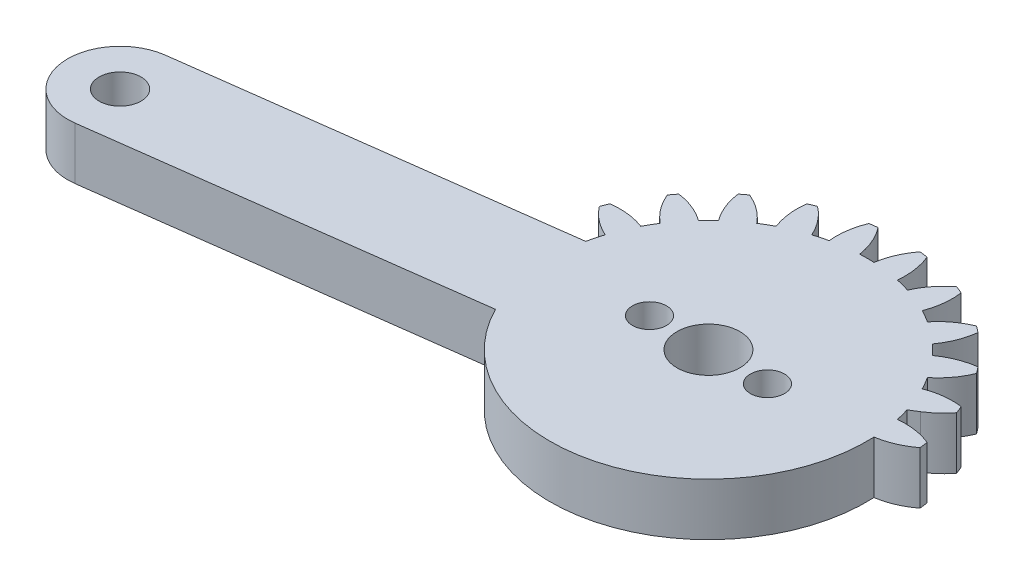
from build123d import *

# Parameters (mm, degrees)
SKETCH1_R           = 1.5
SKETCH1_R_2         = 1.6
BOSS_EXTRUDE1_DEPTH = 4
SKETCH3_R           = 1.6
BOSS_EXTRUDE2_DEPTH = 4
CUT_EXTRUDE1_DEPTH  = 4
CUT_EXTRUDE2_REACH  = 6
SKETCH5_R           = 1.3
SKETCH5_R_2         = 2.4


with BuildPart() as part:
    # Sketch1 → Boss-Extrude1 (new body)
    with BuildSketch(Plane(origin=(0, 0, 0), x_dir=(1, 0, 0), z_dir=(0, 1, 0))):
        with BuildLine():
            Line((20.643657446, 4), (2.081641936, 4))
            ThreePointArc((2.081641936, 4), (2.861028333, 4.588201733), (3.521749436, 5.30713988))
            ThreePointArc((3.521749436, 5.30713988), (3.405395609, 5.596745198), (3.282888305, 5.883801663))
            ThreePointArc((3.282888305, 5.883801663), (1.93527598, 5.894040025), (0.627094961, 5.57027124))
            ThreePointArc((0.627094961, 5.57027124), (0.366286148, 6.046375), (0.084372603, 6.510293938))
            ThreePointArc((0.084372603, 6.510293938), (1.018855105, 7.48132754), (1.683794586, 8.65351323))
            ThreePointArc((1.683794586, 8.65351323), (1.496450048, 8.903135899), (1.303821399, 9.148703928))
            ThreePointArc((1.303821399, 9.148703928), (-0.000522033, 8.809805691), (-1.180330337, 8.158486898))
            ThreePointArc((-1.180330337, 8.158486898), (-1.555477026, 8.550865528), (-1.947855656, 8.926012217))
            ThreePointArc((-1.947855656, 8.926012217), (-1.296536862, 10.105820521), (-0.957638625, 11.410163953))
            ThreePointArc((-0.957638625, 11.410163953), (-1.203206655, 11.602792602), (-1.452829324, 11.79013714))
            ThreePointArc((-1.452829324, 11.79013714), (-2.625015014, 11.125197659), (-3.596048616, 10.190715157))
            ThreePointArc((-3.596048616, 10.190715157), (-4.059967554, 10.472628702), (-4.536071314, 10.733437515))
            ThreePointArc((-4.536071314, 10.733437515), (-4.212302529, 12.041618533), (-4.222540891, 13.389230859))
            ThreePointArc((-4.222540891, 13.389230859), (-4.509597355, 13.511738163), (-4.799202674, 13.62809199))
            ThreePointArc((-4.799202674, 13.62809199), (-5.759348103, 12.682425791), (-6.455432668, 11.528463019))
            ThreePointArc((-6.455432668, 11.528463019), (-6.976508546, 11.680699536), (-7.503891752, 11.809396783))
            ThreePointArc((-7.503891752, 11.809396783), (-7.529737283, 13.156800143), (-7.888414517, 14.455843809))
            ThreePointArc((-7.888414517, 14.455843809), (-8.197396993, 14.499881098), (-8.507248835, 14.537314892))
            ThreePointArc((-8.507248835, 14.537314892), (-9.18992168, 13.375367565), (-9.563620196, 12.080565177))
            ThreePointArc((-9.563620196, 12.080565177), (-10.106342554, 12.09275), (-10.649064912, 12.080565177))
            ThreePointArc((-10.649064912, 12.080565177), (-11.022763428, 13.375367565), (-11.705436272, 14.537314892))
            ThreePointArc((-11.705436272, 14.537314892), (-12.015288115, 14.499881098), (-12.324270591, 14.455843809))
            ThreePointArc((-12.324270591, 14.455843809), (-12.682947825, 13.156800143), (-12.708793355, 11.809396783))
            ThreePointArc((-12.708793355, 11.809396783), (-13.236176561, 11.680699536), (-13.757252439, 11.528463019))
            ThreePointArc((-13.757252439, 11.528463019), (-14.453337005, 12.682425791), (-15.413482434, 13.62809199))
            ThreePointArc((-15.413482434, 13.62809199), (-15.703087752, 13.511738163), (-15.990144217, 13.389230859))
            ThreePointArc((-15.990144217, 13.389230859), (-16.000382579, 12.041618533), (-15.676613793, 10.733437515))
            ThreePointArc((-15.676613793, 10.733437515), (-16.152717554, 10.472628702), (-16.616636492, 10.190715157))
            ThreePointArc((-16.616636492, 10.190715157), (-17.587670094, 11.125197659), (-18.759855783, 11.79013714))
            ThreePointArc((-18.759855783, 11.79013714), (-19.009478453, 11.602792602), (-19.255046482, 11.410163953))
            ThreePointArc((-19.255046482, 11.410163953), (-18.916148245, 10.105820521), (-18.264829452, 8.926012217))
            ThreePointArc((-18.264829452, 8.926012217), (-18.657208082, 8.550865528), (-19.032354771, 8.158486898))
            ThreePointArc((-19.032354771, 8.158486898), (-20.212163074, 8.809805691), (-21.516506507, 9.148703928))
            ThreePointArc((-21.516506507, 9.148703928), (-21.709135156, 8.903135899), (-21.896479694, 8.65351323))
            ThreePointArc((-21.896479694, 8.65351323), (-21.231540213, 7.48132754), (-20.297057711, 6.510293938))
            ThreePointArc((-20.297057711, 6.510293938), (-20.578971255, 6.046375), (-20.839780068, 5.57027124))
            ThreePointArc((-20.839780068, 5.57027124), (-22.147961087, 5.894040025), (-23.495573413, 5.883801663))
            ThreePointArc((-23.495573413, 5.883801663), (-23.618080717, 5.596745198), (-23.734434544, 5.30713988))
            ThreePointArc((-23.734434544, 5.30713988), (-22.788768345, 4.346994451), (-21.634805572, 3.650909885))
            ThreePointArc((-21.634805572, 3.650909885), (-21.78704209, 3.129834008), (-21.915739337, 2.602450802))
            ThreePointArc((-21.915739337, 2.602450802), (-23.263142697, 2.576605271), (-24.562186363, 2.217928037))
            ThreePointArc((-24.562186363, 2.217928037), (-24.606223651, 1.908945561), (-24.643657446, 1.599093719))
            ThreePointArc((-24.643657446, 1.599093719), (-23.481710119, 0.916420874), (-22.186907731, 0.542722358))
            ThreePointArc((-22.186907731, 0.542722358), (-22.199092554, 0), (-22.186907731, -0.542722358))
            ThreePointArc((-22.186907731, -0.542722358), (-23.481710119, -0.916420874), (-24.643657446, -1.599093719))
            ThreePointArc((-24.643657446, -1.599093719), (-24.606223651, -1.908945561), (-24.562186363, -2.217928037))
            ThreePointArc((-24.562186363, -2.217928037), (-23.263142697, -2.576605271), (-21.915739337, -2.602450802))
            ThreePointArc((-21.915739337, -2.602450802), (-21.78704209, -3.129834008), (-21.634805572, -3.650909885))
            ThreePointArc((-21.634805572, -3.650909885), (-22.788768345, -4.346994451), (-23.734434544, -5.30713988))
            ThreePointArc((-23.734434544, -5.30713988), (-23.618080717, -5.596745198), (-23.495573413, -5.883801663))
            ThreePointArc((-23.495573413, -5.883801663), (-22.147961087, -5.894040025), (-20.839780068, -5.57027124))
            ThreePointArc((-20.839780068, -5.57027124), (-20.578971255, -6.046375), (-20.297057711, -6.510293938))
            ThreePointArc((-20.297057711, -6.510293938), (-21.231540213, -7.48132754), (-21.896479694, -8.65351323))
            ThreePointArc((-21.896479694, -8.65351323), (-21.709135156, -8.903135899), (-21.516506507, -9.148703928))
            ThreePointArc((-21.516506507, -9.148703928), (-20.212163074, -8.809805691), (-19.032354771, -8.158486898))
            ThreePointArc((-19.032354771, -8.158486898), (-18.657208082, -8.550865528), (-18.264829452, -8.926012217))
            ThreePointArc((-18.264829452, -8.926012217), (-18.916148245, -10.105820521), (-19.255046482, -11.410163953))
            ThreePointArc((-19.255046482, -11.410163953), (-19.009478453, -11.602792602), (-18.759855783, -11.79013714))
            ThreePointArc((-18.759855783, -11.79013714), (-17.587670094, -11.125197659), (-16.616636492, -10.190715157))
            ThreePointArc((-16.616636492, -10.190715157), (-16.152717554, -10.472628702), (-15.676613793, -10.733437515))
            ThreePointArc((-15.676613793, -10.733437515), (-16.000382579, -12.041618533), (-15.990144217, -13.389230859))
            ThreePointArc((-15.990144217, -13.389230859), (-15.703087752, -13.511738163), (-15.413482434, -13.62809199))
            ThreePointArc((-15.413482434, -13.62809199), (-14.453337005, -12.682425791), (-13.757252439, -11.528463019))
            ThreePointArc((-13.757252439, -11.528463019), (-13.236176561, -11.680699536), (-12.708793355, -11.809396783))
            ThreePointArc((-12.708793355, -11.809396783), (-12.682947825, -13.156800143), (-12.324270591, -14.455843809))
            ThreePointArc((-12.324270591, -14.455843809), (-12.015288115, -14.499881098), (-11.705436272, -14.537314892))
            ThreePointArc((-11.705436272, -14.537314892), (-11.022763428, -13.375367565), (-10.649064912, -12.080565177))
            ThreePointArc((-10.649064912, -12.080565177), (-10.106342554, -12.09275), (-9.563620196, -12.080565177))
            ThreePointArc((-9.563620196, -12.080565177), (-9.18992168, -13.375367565), (-8.507248835, -14.537314892))
            ThreePointArc((-8.507248835, -14.537314892), (-8.197396993, -14.499881098), (-7.888414517, -14.455843809))
            ThreePointArc((-7.888414517, -14.455843809), (-7.529737283, -13.156800143), (-7.503891752, -11.809396783))
            ThreePointArc((-7.503891752, -11.809396783), (-6.976508546, -11.680699536), (-6.455432668, -11.528463019))
            ThreePointArc((-6.455432668, -11.528463019), (-5.759348103, -12.682425791), (-4.799202674, -13.62809199))
            ThreePointArc((-4.799202674, -13.62809199), (-4.509597355, -13.511738163), (-4.222540891, -13.389230859))
            ThreePointArc((-4.222540891, -13.389230859), (-4.212302529, -12.041618533), (-4.536071314, -10.733437515))
            ThreePointArc((-4.536071314, -10.733437515), (-4.059967554, -10.472628702), (-3.596048616, -10.190715157))
            ThreePointArc((-3.596048616, -10.190715157), (-2.625015014, -11.125197659), (-1.452829324, -11.79013714))
            ThreePointArc((-1.452829324, -11.79013714), (-1.203206655, -11.602792602), (-0.957638625, -11.410163953))
            ThreePointArc((-0.957638625, -11.410163953), (-1.296536862, -10.105820521), (-1.947855656, -8.926012217))
            ThreePointArc((-1.947855656, -8.926012217), (-1.555477026, -8.550865528), (-1.180330337, -8.158486898))
            ThreePointArc((-1.180330337, -8.158486898), (-0.000522033, -8.809805691), (1.303821399, -9.148703928))
            ThreePointArc((1.303821399, -9.148703928), (1.496450048, -8.903135899), (1.683794586, -8.65351323))
            ThreePointArc((1.683794586, -8.65351323), (1.018855105, -7.48132754), (0.084372603, -6.510293938))
            ThreePointArc((0.084372603, -6.510293938), (0.366286148, -6.046375), (0.627094961, -5.57027124))
            ThreePointArc((0.627094961, -5.57027124), (1.93527598, -5.894040025), (3.282888305, -5.883801663))
            ThreePointArc((3.282888305, -5.883801663), (3.405395609, -5.596745198), (3.521749436, -5.30713988))
            ThreePointArc((3.521749436, -5.30713988), (2.861028333, -4.588201733), (2.081641936, -4))
            Line((2.081641936, -4), (20.643657446, -4))
            ThreePointArc((20.643657446, -4), (24.643657446, 0), (20.643657446, 4))
        make_face()
        with Locations((-10.106342554, 0)):
            Circle(SKETCH1_R, mode=Mode.SUBTRACT)
        with Locations((20.643657446, 0)):
            Circle(SKETCH1_R_2, mode=Mode.SUBTRACT)
    extrude(amount=BOSS_EXTRUDE1_DEPTH)

    # Sketch3 → Boss-Extrude2 (add)
    with BuildSketch(Plane(origin=(0, 4, 0), x_dir=(1, 0, 0), z_dir=(0, 1, 0))):
        with BuildLine():
            ThreePointArc((-9.584237785, -3.965779445), (-14.072121999, -0.522104769), (-10.628447323, 3.965779445))
            Line((-10.628447323, 3.965779445), (-50.286241778, -1.255268243))
            ThreePointArc((-50.286241778, -1.255268243), (-53.729916454, -5.743152458), (-49.24203224, -9.186827134))
            Line((-49.24203224, -9.186827134), (-9.584237785, -3.965779445))
        make_face()
        with Locations((-49.764137009, -5.221047689)):
            Circle(SKETCH3_R, mode=Mode.SUBTRACT)
    extrude(amount=-BOSS_EXTRUDE2_DEPTH)

    # Sketch4 → Cut-Extrude1 (cut)
    with BuildSketch(Plane(origin=(0, 4, 0), x_dir=(1, 0, 0), z_dir=(0, 1, 0))):
        with BuildLine():
            ThreePointArc((20.643657446, -4), (24.643657446, 0), (20.643657446, 4))
            Line((20.643657446, 4), (2.081641936, 4))
            Line((2.081641936, 4), (1.43808022, 3.600125745))
            ThreePointArc((1.43808022, 3.600125745), (1.581217534, 3.104116905), (1.70305423, 2.602450802))
            ThreePointArc((1.70305423, 2.602450802), (3.050457589, 2.576605271), (4.349501255, 2.217928037))
            ThreePointArc((4.349501255, 2.217928037), (4.393538544, 1.908945561), (4.430972339, 1.599093719))
            ThreePointArc((4.430972339, 1.599093719), (3.269025011, 0.916420874), (1.974222624, 0.542722358))
            ThreePointArc((1.974222624, 0.542722358), (1.70305423, -2.602450802), (0.627094961, -5.57027124))
            ThreePointArc((0.627094961, -5.57027124), (1.93527598, -5.894040025), (3.282888305, -5.883801663))
            ThreePointArc((3.282888305, -5.883801663), (3.405395609, -5.596745198), (3.521749436, -5.30713988))
            ThreePointArc((3.521749436, -5.30713988), (2.861028333, -4.588201733), (2.081641936, -4))
            Line((2.081641936, -4), (20.643657446, -4))
        make_face()
        with BuildLine():
            ThreePointArc((1.683794586, -8.65351323), (1.018855105, -7.48132754), (0.084372603, -6.510293938))
            ThreePointArc((0.084372603, -6.510293938), (-0.512518948, -7.361599771), (-1.180330337, -8.158486898))
            ThreePointArc((-1.180330337, -8.158486898), (-0.000522033, -8.809805691), (1.303821399, -9.148703928))
            ThreePointArc((1.303821399, -9.148703928), (1.496450048, -8.903135899), (1.683794586, -8.65351323))
        make_face()
        with BuildLine():
            ThreePointArc((-0.957638625, -11.410163953), (-1.296536862, -10.105820521), (-1.947855656, -8.926012217))
            ThreePointArc((-1.947855656, -8.926012217), (-2.744742783, -9.593823606), (-3.596048616, -10.190715157))
            ThreePointArc((-3.596048616, -10.190715157), (-2.625015014, -11.125197659), (-1.452829324, -11.79013714))
            ThreePointArc((-1.452829324, -11.79013714), (-1.203206655, -11.602792602), (-0.957638625, -11.410163953))
        make_face()
        with BuildLine():
            ThreePointArc((-4.222540891, -13.389230859), (-4.212302529, -12.041618533), (-4.536071314, -10.733437515))
            ThreePointArc((-4.536071314, -10.733437515), (-5.478647477, -11.172244217), (-6.455432668, -11.528463019))
            ThreePointArc((-6.455432668, -11.528463019), (-5.759348103, -12.682425791), (-4.799202674, -13.62809199))
            ThreePointArc((-4.799202674, -13.62809199), (-4.509597355, -13.511738163), (-4.222540891, -13.389230859))
        make_face()
        with BuildLine():
            ThreePointArc((-7.888414517, -14.455843809), (-7.529737283, -13.156800143), (-7.503891752, -11.809396783))
            ThreePointArc((-7.503891752, -11.809396783), (-8.527921943, -11.989294847), (-9.563620196, -12.080565177))
            ThreePointArc((-9.563620196, -12.080565177), (-9.18992168, -13.375367565), (-8.507248835, -14.537314892))
            ThreePointArc((-8.507248835, -14.537314892), (-8.197396993, -14.499881098), (-7.888414517, -14.455843809))
        make_face()
        with BuildLine():
            ThreePointArc((-11.705436272, -14.537314892), (-11.022763428, -13.375367565), (-10.649064912, -12.080565177))
            ThreePointArc((-10.649064912, -12.080565177), (-11.684763165, -11.989294847), (-12.708793355, -11.809396783))
            ThreePointArc((-12.708793355, -11.809396783), (-12.682947825, -13.156800143), (-12.324270591, -14.455843809))
            ThreePointArc((-12.324270591, -14.455843809), (-12.015288115, -14.499881098), (-11.705436272, -14.537314892))
        make_face()
        with BuildLine():
            ThreePointArc((-15.413482434, -13.62809199), (-14.453337005, -12.682425791), (-13.757252439, -11.528463019))
            ThreePointArc((-13.757252439, -11.528463019), (-14.734037631, -11.172244217), (-15.676613793, -10.733437515))
            ThreePointArc((-15.676613793, -10.733437515), (-16.000382579, -12.041618533), (-15.990144217, -13.389230859))
            ThreePointArc((-15.990144217, -13.389230859), (-15.703087752, -13.511738163), (-15.413482434, -13.62809199))
        make_face()
        with BuildLine():
            ThreePointArc((-18.759855783, -11.79013714), (-17.587670094, -11.125197659), (-16.616636492, -10.190715157))
            ThreePointArc((-16.616636492, -10.190715157), (-17.467942324, -9.593823606), (-18.264829452, -8.926012217))
            ThreePointArc((-18.264829452, -8.926012217), (-18.916148245, -10.105820521), (-19.255046482, -11.410163953))
            ThreePointArc((-19.255046482, -11.410163953), (-19.009478453, -11.602792602), (-18.759855783, -11.79013714))
        make_face()
        with BuildLine():
            ThreePointArc((-21.516506507, -9.148703928), (-20.212163074, -8.809805691), (-19.032354771, -8.158486898))
            ThreePointArc((-19.032354771, -8.158486898), (-19.70016616, -7.361599771), (-20.297057711, -6.510293938))
            ThreePointArc((-20.297057711, -6.510293938), (-21.231540213, -7.48132754), (-21.896479694, -8.65351323))
            ThreePointArc((-21.896479694, -8.65351323), (-21.709135156, -8.903135899), (-21.516506507, -9.148703928))
        make_face()
        with BuildLine():
            ThreePointArc((-21.942853375, 2.47620963), (-21.92946485, 2.539366405), (-21.915739337, 2.602450802))
            ThreePointArc((-21.915739337, 2.602450802), (-23.263142697, 2.576605271), (-24.562186363, 2.217928037))
            ThreePointArc((-24.562186363, 2.217928037), (-24.56889027, 2.173784387), (-24.575459377, 2.129620475))
            Line((-24.575459377, 2.129620475), (-21.942853375, 2.47620963))
        make_face()
        with BuildLine():
            ThreePointArc((-23.495573413, -5.883801663), (-22.147961087, -5.894040025), (-20.839780068, -5.57027124))
            ThreePointArc((-20.839780068, -5.57027124), (-20.869365339, -5.512888815), (-20.898643838, -5.455349261))
            Line((-20.898643838, -5.455349261), (-23.531249839, -5.801938416))
            ThreePointArc((-23.531249839, -5.801938416), (-23.513474108, -5.842897269), (-23.495573413, -5.883801663))
        make_face()
    extrude(amount=-CUT_EXTRUDE1_DEPTH, mode=Mode.SUBTRACT)

    # Sketch5 → Cut-Extrude2 (cut, up to next)
    with BuildSketch(Plane(origin=(0, 4, 0), x_dir=(1, 0, 0), z_dir=(0, 1, 0)), mode=Mode.PRIVATE) as cut_extrude2_sk1:
        with Locations((-14.606342554, 0)):
            Circle(SKETCH5_R)
    cut_extrude2_tool1 = extrude(cut_extrude2_sk1.sketch, amount=-CUT_EXTRUDE2_REACH, mode=Mode.PRIVATE) & part.part
    add(cut_extrude2_tool1.solids().sort_by_distance((-14.606343, 4, 0))[0], mode=Mode.SUBTRACT)
    # Sketch5 → Cut-Extrude2 (cut, up to next)
    with BuildSketch(Plane(origin=(0, 4, 0), x_dir=(1, 0, 0), z_dir=(0, 1, 0)), mode=Mode.PRIVATE) as cut_extrude2_sk2:
        with Locations((-5.606342554, 0)):
            Circle(SKETCH5_R)
    cut_extrude2_tool2 = extrude(cut_extrude2_sk2.sketch, amount=-CUT_EXTRUDE2_REACH, mode=Mode.PRIVATE) & part.part
    add(cut_extrude2_tool2.solids().sort_by_distance((-5.606343, 4, 0))[0], mode=Mode.SUBTRACT)
    # Sketch5 → Cut-Extrude2 (cut, up to next)
    with BuildSketch(Plane(origin=(0, 4, 0), x_dir=(1, 0, 0), z_dir=(0, 1, 0)), mode=Mode.PRIVATE) as cut_extrude2_sk3:
        with Locations((-10.106342554, 0)):
            Circle(SKETCH5_R_2)
    cut_extrude2_tool3 = extrude(cut_extrude2_sk3.sketch, amount=-CUT_EXTRUDE2_REACH, mode=Mode.PRIVATE) & part.part
    add(cut_extrude2_tool3.solids().sort_by_distance((-10.106343, 4, 0))[0], mode=Mode.SUBTRACT)


solid = part.part
